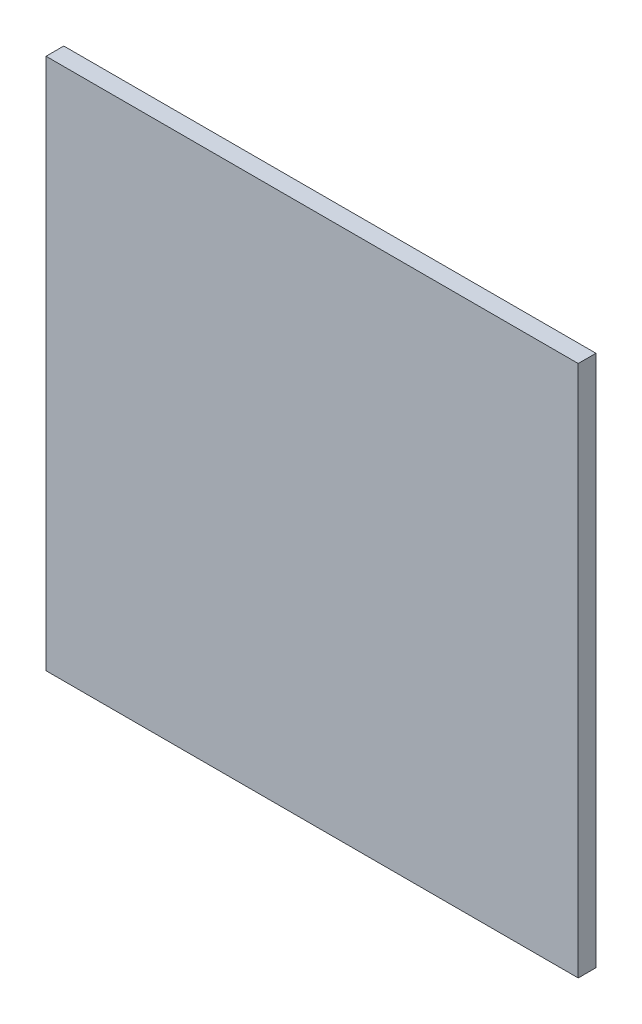
from build123d import *

# Parameters (mm, degrees)
ESQUISSE1_W        = 120
ESQUISSE1_H        = 120
BOSS_EXTRU_1_DEPTH = 4


with BuildPart() as part:
    # Esquisse1 → Boss.-Extru.1 (new body)
    with BuildSketch(Plane.XY):
        with Locations((60, 60)):
            Rectangle(ESQUISSE1_W, ESQUISSE1_H)
    extrude(amount=BOSS_EXTRU_1_DEPTH)


solid = part.part
